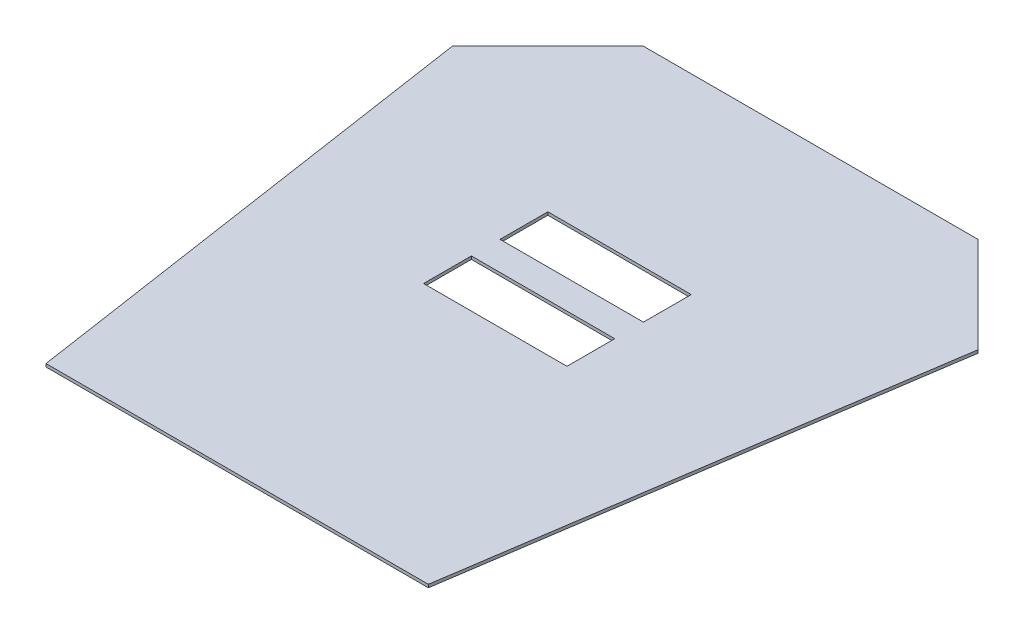
from build123d import *

# Parameters (mm, degrees)
BOSS_EXTRUDE1_DEPTH = 3.175
SKETCH2_W           = 150
SKETCH2_H           = 50
CUT_EXTRUDE1_DEPTH  = 10


with BuildPart() as part:
    # Sketch1 → Boss-Extrude1 (new body)
    with BuildSketch(Plane(origin=(0, 0, 0), x_dir=(1, 0, 0), z_dir=(0, 1, 0))):
        Polygon((-175, 100), (175, 100), (275, 0), (200, -500), (-200, -500), (-275, 0), align=None)
    extrude(amount=BOSS_EXTRUDE1_DEPTH)

    # Sketch2 → Cut-Extrude1 (cut)
    with BuildSketch(Plane(origin=(0, 3.175, 0), x_dir=(1, 0, 0), z_dir=(0, 1, 0))):
        with Locations((0, -205)):
            Rectangle(SKETCH2_W, SKETCH2_H)
        with Locations((0, -125)):
            Rectangle(SKETCH2_W, SKETCH2_H)
    extrude(amount=-CUT_EXTRUDE1_DEPTH, mode=Mode.SUBTRACT)


solid = part.part
